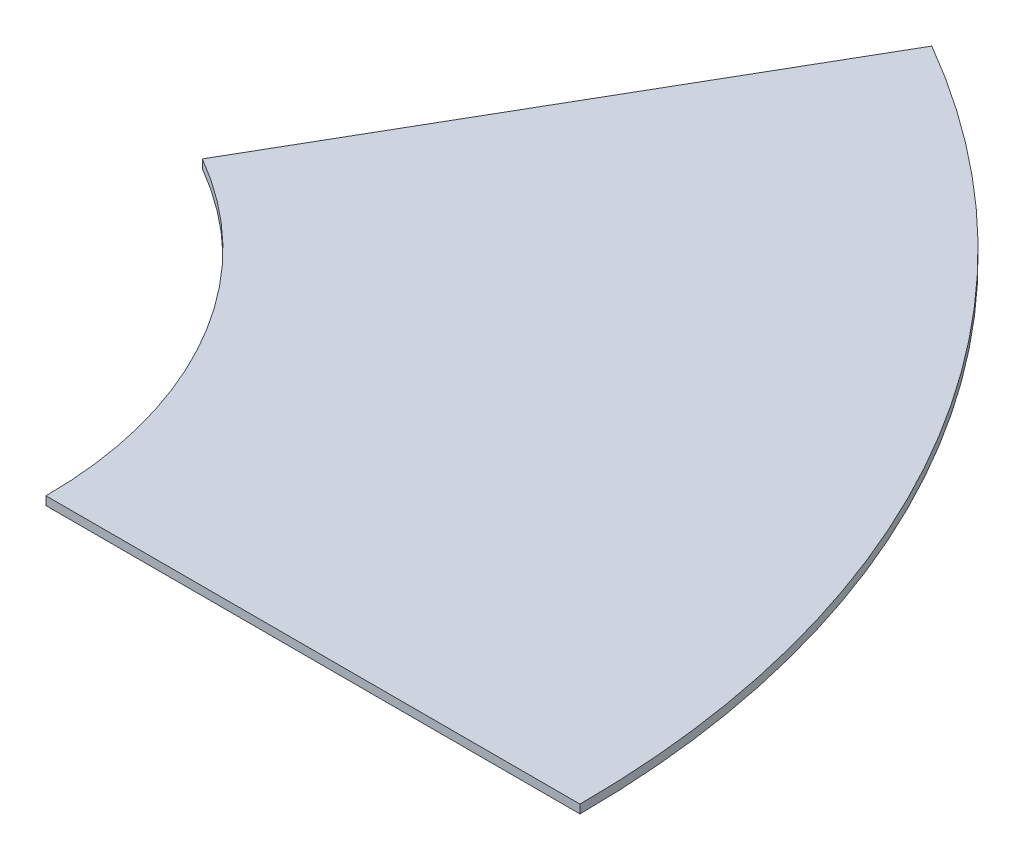
from build123d import *

# Parameters (mm, degrees)
BOSS_EXTRU_2_DEPTH = 0.2


with BuildPart() as part:
    # Esquisse1 → Boss.-Extru.2 (new body)
    with BuildSketch(Plane(origin=(0, 0, 0), x_dir=(1, 0, 0), z_dir=(0, 1, 0))):
        with BuildLine():
            Line((10, 0), (22.5, 0))
            ThreePointArc((22.5, 0), (19.485571585, 11.25), (11.25, 19.485571585))
            Line((11.25, 19.485571585), (5, 8.660254038))
            ThreePointArc((5, 8.660254038), (8.660254038, 5), (10, 0))
        make_face()
    extrude(amount=-BOSS_EXTRU_2_DEPTH)


solid = part.part
